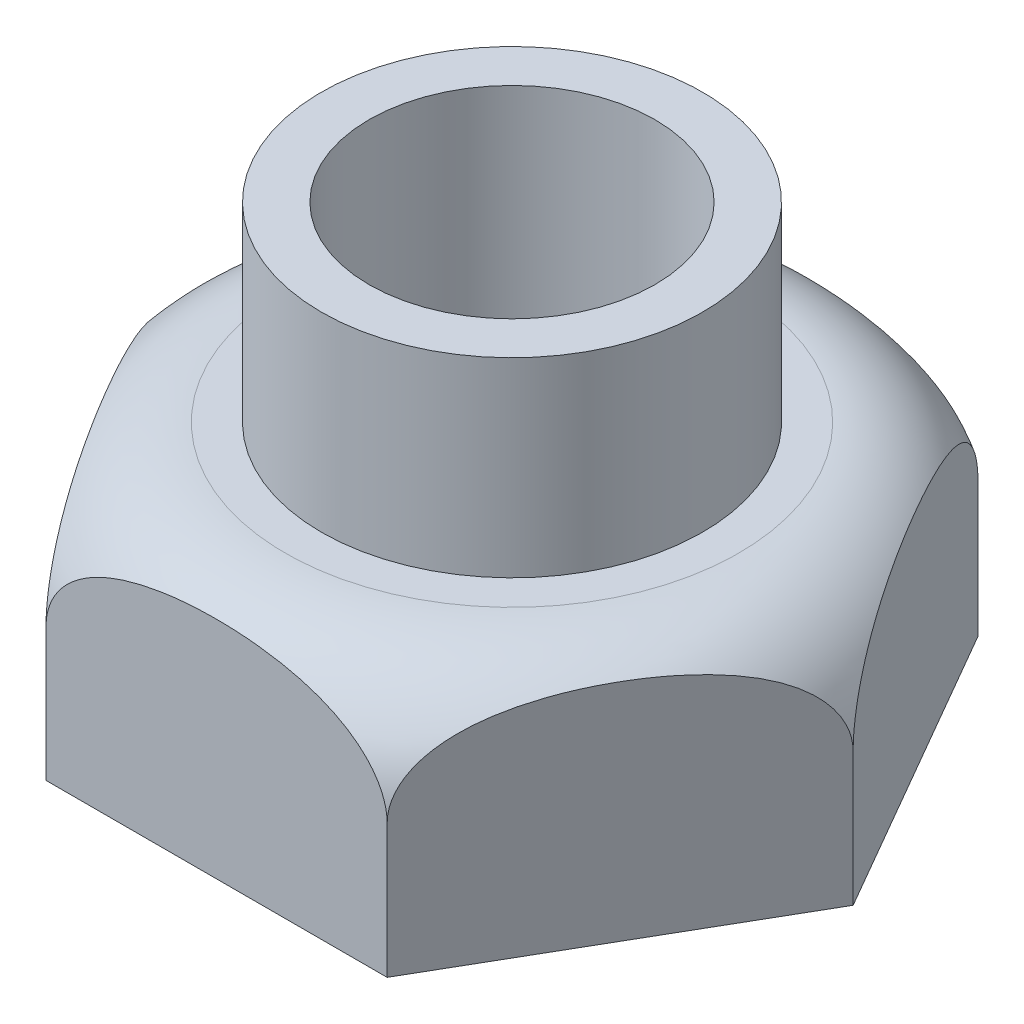
from build123d import *

# Parameters (mm, degrees)
BOSS_EXTRUDE1_DEPTH = 32.5
SKETCH3_R           = 50
SKETCH3_R_2         = 37.5
BOSS_EXTRUDE2_DEPTH = 50
SKETCH4_R           = 37.5
CUT_EXTRUDE1_DEPTH  = 94


with BuildPart() as part:
    # Sketch1 → Boss-Extrude1 (new body, symmetric)
    with BuildSketch(Plane(origin=(0, 0, 0), x_dir=(1, 0, 0), z_dir=(0, 1, 0))):
        Polygon((-89.489291724, 0), (-44.744645862, -77.5), (44.744645862, -77.5), (89.489291724, 0), (44.744645862, 77.5), (-44.744645862, 77.5), align=None)
    extrude(amount=BOSS_EXTRUDE1_DEPTH, both=True)

    # Sketch2 → Cut-Revolve1 (revolve, cut)
    with BuildSketch(Plane.XY):
        with BuildLine():
            Line((-59.489291724, 32.5), (-57.951385683, 32.5))
            Line((-57.951385683, 32.5), (-79.245811776, 59.780712904))
            Line((-79.245811776, 59.780712904), (-106.219123603, 23.051452734))
            Line((-106.219123603, 23.051452734), (-89.489291724, -3.938998624))
            Line((-89.489291724, -3.938998624), (-89.489291724, 2.5))
            ThreePointArc((-89.489291724, 2.5), (-80.70249516, 23.713203436), (-59.489291724, 32.5))
        make_face()
    revolve(axis=Axis((0, 0, 0), (0, 1, 0)), mode=Mode.SUBTRACT)

    # Sketch3 → Boss-Extrude2 (add)
    with BuildSketch(Plane(origin=(0, 32.5, 0), x_dir=(1, 0, 0), z_dir=(0, 1, 0))):
        Circle(SKETCH3_R)
        Circle(SKETCH3_R_2, mode=Mode.SUBTRACT)
    extrude(amount=BOSS_EXTRUDE2_DEPTH)

    # Sketch4 → Cut-Extrude1 (cut)
    with BuildSketch(Plane(origin=(0, 32.5, 0), x_dir=(1, 0, 0), z_dir=(0, 1, 0))):
        Circle(SKETCH4_R)
    extrude(amount=-CUT_EXTRUDE1_DEPTH, mode=Mode.SUBTRACT)


solid = part.part
